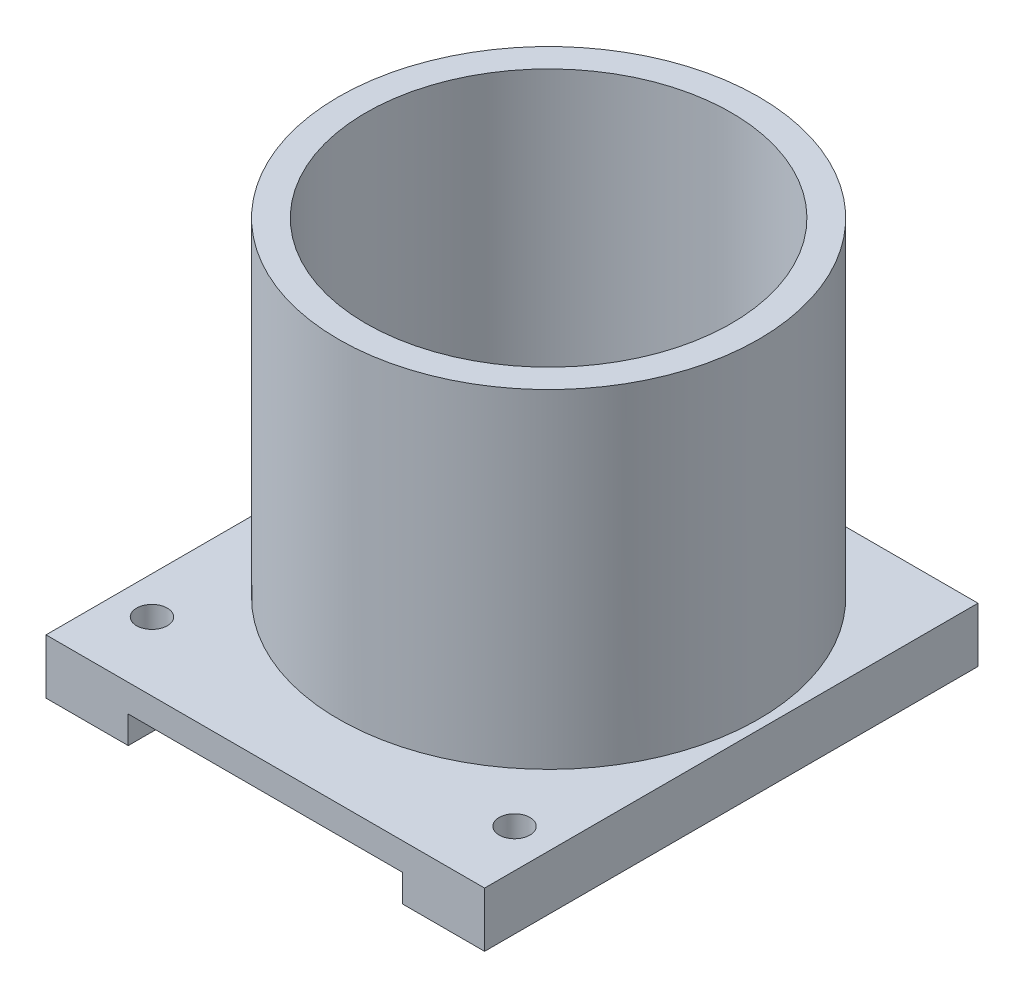
from build123d import *

# Parameters (mm, degrees)
SKETCH1_R                 = 12.1666
SKETCH1_R_2               = 10.5791
BOSS_EXTRUDE1_DEPTH       = 19.05
SKETCH2_W                 = 25.4
SKETCH2_H                 = 28.575
BOSS_EXTRUDE2_DEPTH       = 3.175
SKETCH3_R                 = 6.35
CUT_EXTRUDE1_DEPTH        = 23.225
SKETCH8_R                 = 10.5791
SKETCH8_R_2               = 6.35
BOSS_EXTRUDE4_DEPTH       = 0.127
SKETCH9_R                 = 10.5791
SKETCH9_R_2               = 3.96875
BOSS_EXTRUDE5_DEPTH       = 3.175
F_2_56_TAPPED_HOLE1_D     = 1.778
F_2_56_TAPPED_HOLE1_DEPTH = 5.588
F_2_56_TAPPED_HOLE1_TIP   = 0.53416509
SKETCH6_W                 = 15.875
SKETCH6_H                 = 37.082262956
CUT_EXTRUDE2_DEPTH        = 1.5875


with BuildPart() as part:
    # Sketch1 → Boss-Extrude1 (new body)
    with BuildSketch(Plane(origin=(0, 0, 0), x_dir=(1, 0, 0), z_dir=(0, 1, 0))):
        Circle(SKETCH1_R)
        Circle(SKETCH1_R_2, mode=Mode.SUBTRACT)
    extrude(amount=BOSS_EXTRUDE1_DEPTH)

    # Sketch2 → Boss-Extrude2 (add)
    with BuildSketch(Plane.XZ):
        with Locations((0, 2.1209)):
            Rectangle(SKETCH2_W, SKETCH2_H)
    extrude(amount=BOSS_EXTRUDE2_DEPTH)

    # Sketch3 → Cut-Extrude1 (cut, through all)
    with BuildSketch(Plane.XZ.offset(3.175)):
        Circle(SKETCH3_R)
    extrude(amount=-CUT_EXTRUDE1_DEPTH, mode=Mode.SUBTRACT)

    # Sketch8 → Boss-Extrude4 (add)
    with BuildSketch(Plane(origin=(0, 0, 0), x_dir=(1, 0, 0), z_dir=(0, 1, 0))):
        Circle(SKETCH8_R)
        Circle(SKETCH8_R_2, mode=Mode.SUBTRACT)
    extrude(amount=BOSS_EXTRUDE4_DEPTH)

    # Sketch9 → Boss-Extrude5 (add)
    with BuildSketch(Plane(origin=(0, 0.127, 0), x_dir=(1, 0, 0), z_dir=(0, 1, 0))):
        Circle(SKETCH9_R)
        Circle(SKETCH9_R_2, mode=Mode.SUBTRACT)
    extrude(amount=BOSS_EXTRUDE5_DEPTH)

    # #2-56 Tapped Hole1
    with Locations(Plane(origin=(0, -3.175, 0), x_dir=(-1, 0, 0), z_dir=(0, -1, 0))):
        with Locations((10.531523735, -12.441379328), (10.531523735, 0.058620672), (-10.468476265, -12.441379328), (-10.468476265, 0.058620672)):
            Hole(F_2_56_TAPPED_HOLE1_D / 2, depth=F_2_56_TAPPED_HOLE1_DEPTH)
            with Locations((0, 0, -(F_2_56_TAPPED_HOLE1_DEPTH + F_2_56_TAPPED_HOLE1_TIP / 2))):  # 118° drill point
                Cone(0, F_2_56_TAPPED_HOLE1_D / 2, F_2_56_TAPPED_HOLE1_TIP, mode=Mode.SUBTRACT)

    # Sketch6 → Cut-Extrude2 (cut)
    with BuildSketch(Plane.XZ.offset(3.175)):
        Rectangle(SKETCH6_W, SKETCH6_H)
    extrude(amount=-CUT_EXTRUDE2_DEPTH, mode=Mode.SUBTRACT)


solid = part.part
